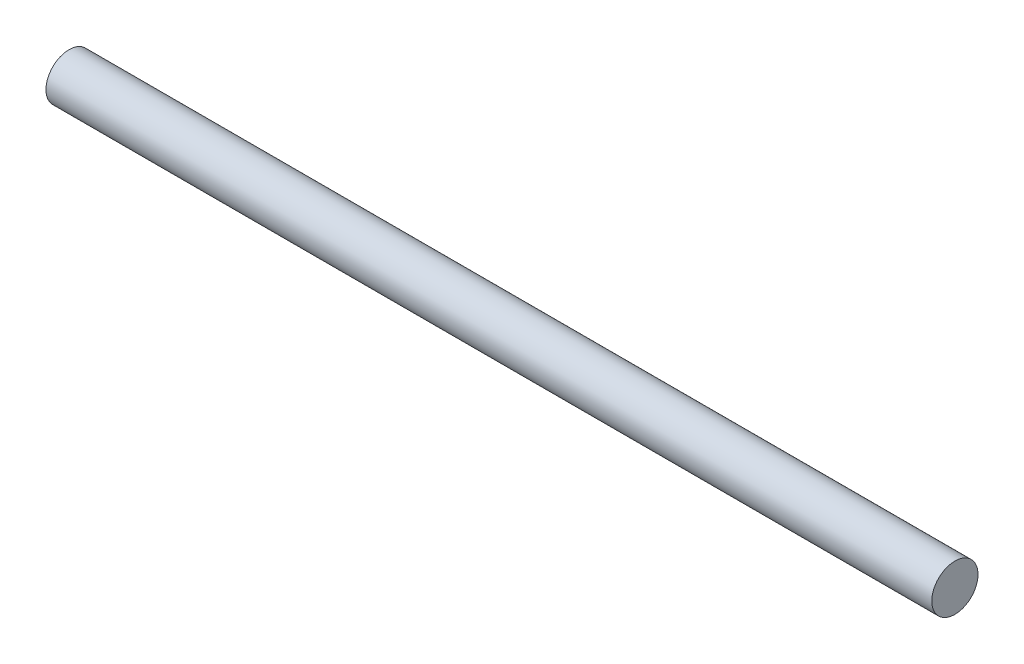
from build123d import *

# Parameters (mm, degrees)
BOSS_EXTRUDE1_DEPTH      = 125
BOSS_EXTRUDE1_DEPTH_BACK = 125
SKETCH1_R                = 6.522988495


with BuildPart() as part:
    # Sketch1 → Boss-Extrude1 (new, two sides: drawn at the far end of the back side and taken through both)
    with BuildSketch(Plane(origin=(0, 0, 0), x_dir=(0, 0, -1), z_dir=(1, 0, 0)).offset(-BOSS_EXTRUDE1_DEPTH_BACK)):
        Circle(SKETCH1_R)
    extrude(amount=BOSS_EXTRUDE1_DEPTH + BOSS_EXTRUDE1_DEPTH_BACK)


solid = part.part
